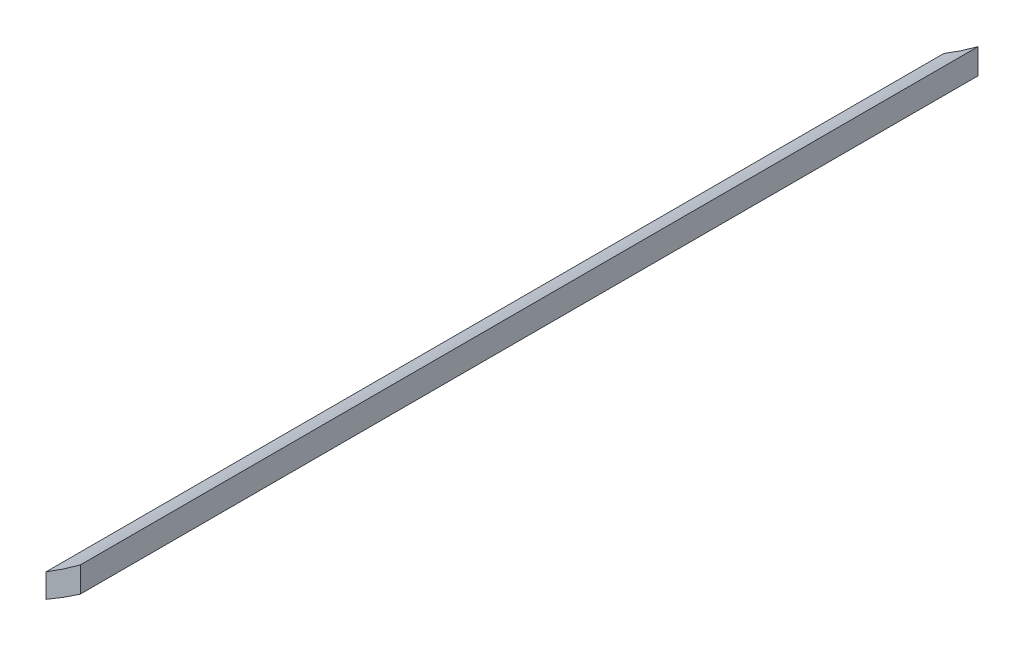
from build123d import *

# Parameters (mm, degrees)
BOSS_EXTRUDE1_DEPTH = 55


with BuildPart() as part:
    # Sketch1 → Boss-Extrude1 (new body)
    with BuildSketch(Plane.XY):
        with BuildLine():
            Line((124.25842281, -49.206656057), (124.25842281, -50.756201419))
            add(Edge.make_bspline(
                [(122.15842281, -52.081913765), (122.466925521, -51.907939931), (122.771253519, -51.726792802), (123.473575804, -51.288883163), (123.868912345, -51.027058817), (124.25842281, -50.756201419)],
                knots=[0.649205425, 0.649205425, 0.649205425, 0.649205425, 0.75, 0.75, 0.885223183, 0.885223183, 0.885223183, 0.885223183], degree=3))
            Line((122.15842281, -52.081913765), (122.15842281, -50.622044002))
            add(Edge.make_bspline(
                [(124.25842281, -49.206656057), (123.864604952, -49.496768366), (123.464989768, -49.778427885), (122.762284683, -50.246279719), (122.462623418, -50.437471155), (122.15842281, -50.622044002)],
                knots=[0.11406222, 0.11406222, 0.11406222, 0.11406222, 0.25, 0.25, 0.348787923, 0.348787923, 0.348787923, 0.348787923], degree=3))
        make_face()
    extrude(amount=BOSS_EXTRUDE1_DEPTH)


solid = part.part
